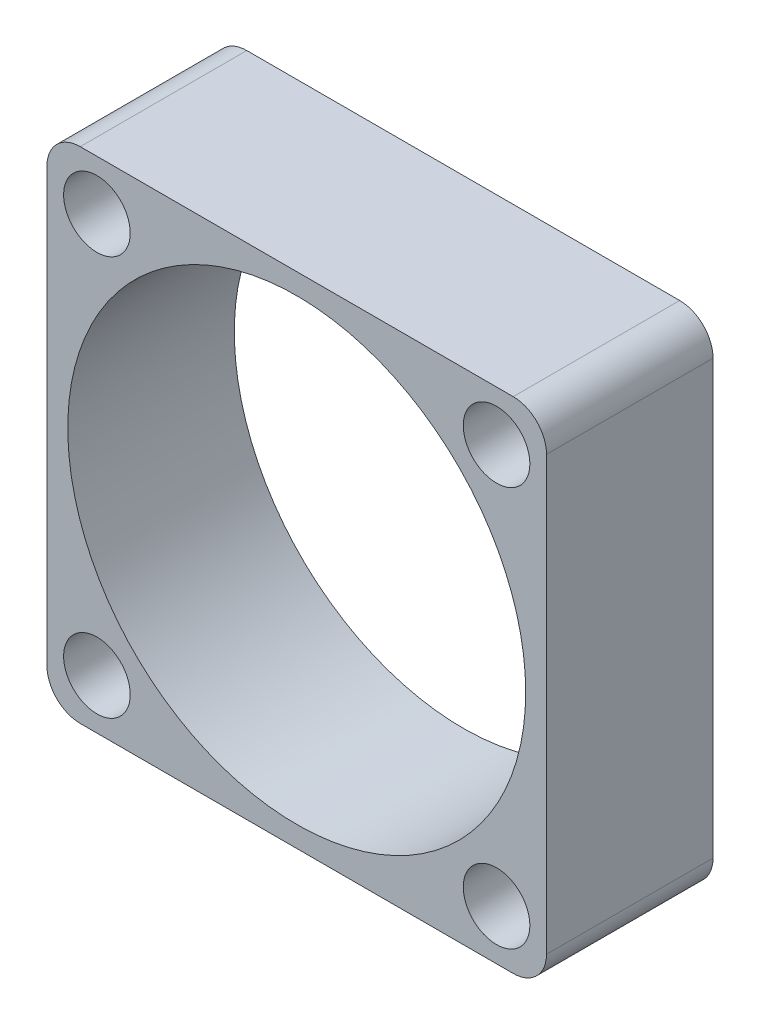
from build123d import *

# Parameters (mm, degrees)
SKETCH1_W           = 30
SKETCH1_H           = 30
BOSS_EXTRUDE1_DEPTH = 10
SKETCH3_R           = 13.75
SKETCH3_R_2         = 2
CUT_EXTRUDE1_DEPTH  = 10
FILLET1_R           = 2


with BuildPart() as part:
    # Sketch1 → Boss-Extrude1 (new body)
    with BuildSketch(Plane.XY):
        with Locations((15, 15)):
            Rectangle(SKETCH1_W, SKETCH1_H)
    extrude(amount=BOSS_EXTRUDE1_DEPTH)

    # Sketch3 → Cut-Extrude1 (cut)
    with BuildSketch(Plane.XY.offset(10)):
        with Locations((15, 15)):
            Circle(SKETCH3_R)
        with Locations((3, 27)):
            Circle(SKETCH3_R_2)
        with Locations((3, 3)):
            Circle(SKETCH3_R_2)
        with Locations((27, 3)):
            Circle(SKETCH3_R_2)
        with Locations((27, 27)):
            Circle(SKETCH3_R_2)
    extrude(amount=-CUT_EXTRUDE1_DEPTH, mode=Mode.SUBTRACT)

    # Fillet1
    fillet1_edges = [part.edges().sort_by_distance(p)[0] for p in [
        (0, 30, 5),
        (30, 30, 5),
        (30, 0, 5),
        (0, 0, 5),
    ]]
    fillet(fillet1_edges, radius=FILLET1_R)


solid = part.part
